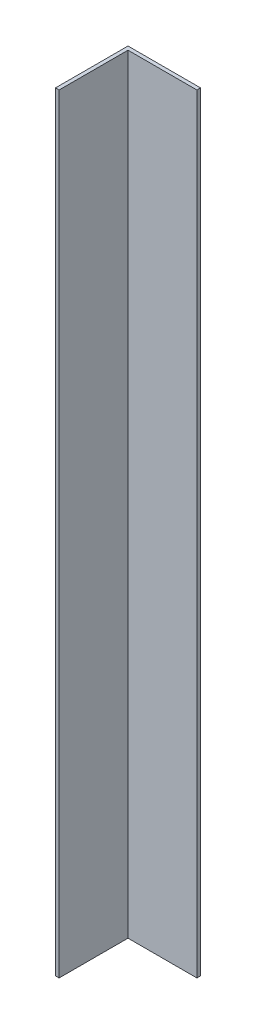
from build123d import *

# Parameters (mm, degrees)
BOSS_EXTRU_1_DEPTH = 424


with BuildPart() as part:
    # Esquisse1 → Boss.-Extru.1 (new body)
    with BuildSketch(Plane(origin=(0, 0, 0), x_dir=(1, 0, 0), z_dir=(0, 1, 0))):
        Polygon((-20, 20.113636364), (20, 20.113636364), (20, 18.113636364), (-18, 18.113636364), (-18, -19.886363636), (-20, -19.886363636), align=None)
    extrude(amount=BOSS_EXTRU_1_DEPTH)


solid = part.part
